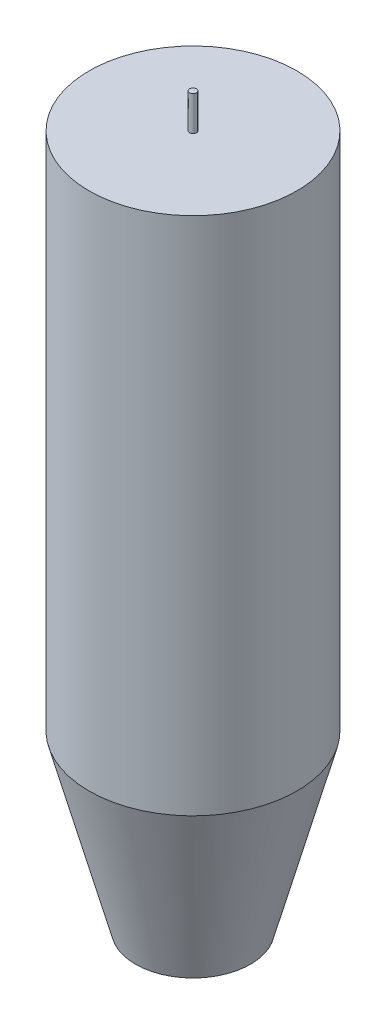
from build123d import *

# Parameters (mm, degrees)
SKETCH2_R           = 15
BOSS_EXTRUDE1_DEPTH = 100
CHAMFER1_SIZE       = 25
CHAMFER1_SIZE2      = 6.698729811
SKETCH3_R           = 0.5
BOSS_EXTRUDE2_DEPTH = 5


with BuildPart() as part:
    # Sketch2 → Boss-Extrude1 (new body)
    with BuildSketch(Plane(origin=(0, 0, 0), x_dir=(1, 0, 0), z_dir=(0, 1, 0))):
        Circle(SKETCH2_R)
    extrude(amount=BOSS_EXTRUDE1_DEPTH)

    # Chamfer1
    chamfer1_edges = [part.edges().sort_by_distance(p)[0] for p in [
        (-15, 0, 0),
    ]]
    chamfer1_side = [part.faces().sort_by_distance(p)[0] for p in [
        (-15, 50, 0),
    ]]
    chamfer(chamfer1_edges, length=CHAMFER1_SIZE, length2=CHAMFER1_SIZE2, reference=chamfer1_side[0])

    # Sketch3 → Boss-Extrude2 (add)
    with BuildSketch(Plane(origin=(0, 100, 0), x_dir=(1, 0, 0), z_dir=(0, 1, 0))):
        Circle(SKETCH3_R)
    extrude(amount=BOSS_EXTRUDE2_DEPTH)


solid = part.part
